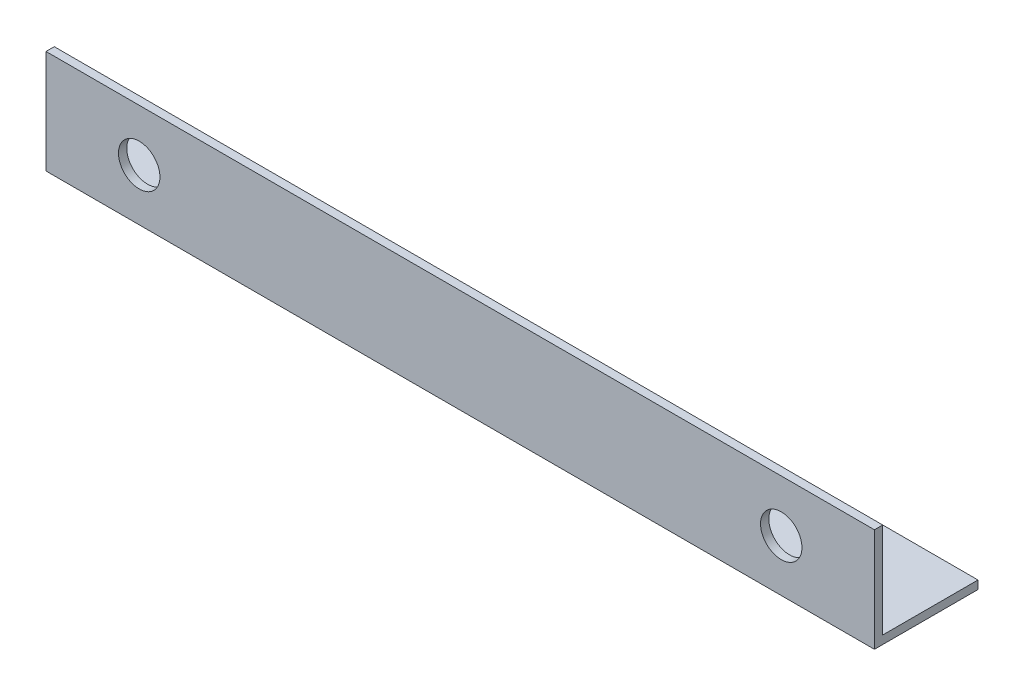
from build123d import *

# Parameters (mm, degrees)
EXTRUDE_1_DEPTH     = 200
SKETCH_2_R          = 5
CUT_EXTRUDE_1_DEPTH = 26


with BuildPart() as part:
    # Эскиз1 → Вытянуть-Тонкостенный1 (new body)
    with BuildSketch(Plane(origin=(0, 0, 0), x_dir=(0, 0, -1), z_dir=(1, 0, 0))):
        Polygon((0, 25), (0, 0), (25, 0), (25, 2), (2, 2), (2, 25), align=None)
    extrude(amount=EXTRUDE_1_DEPTH)

    # Эскиз2 → Вырез-Вытянуть1 (cut, through all)
    with BuildSketch(Plane.XY):
        with Locations((22.5, 12.5)):
            Circle(SKETCH_2_R)
        with Locations((177.5, 12.5)):
            Circle(SKETCH_2_R)
    extrude(amount=-CUT_EXTRUDE_1_DEPTH, mode=Mode.SUBTRACT)


solid = part.part
